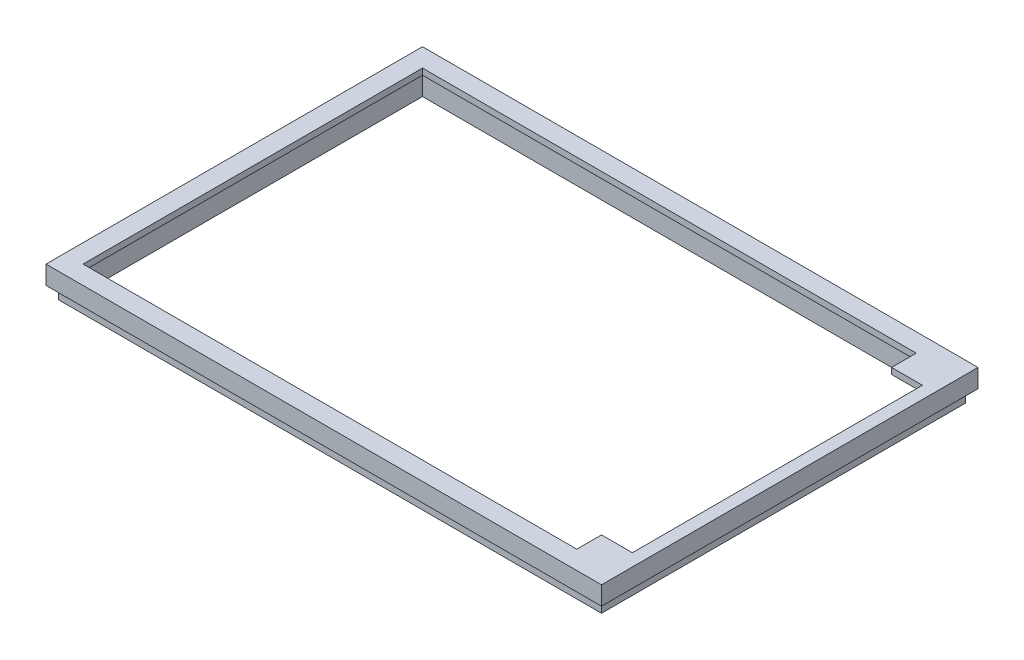
from build123d import *

# Parameters (mm, degrees)
SKETCH1_W           = 90
SKETCH1_H           = 61
SKETCH1_W_2         = 86
SKETCH1_H_2         = 57
BOSS_EXTRUDE1_DEPTH = 3
BOSS_EXTRUDE2_DEPTH = 1
SKETCH3_W           = 88
SKETCH3_H           = 59
SKETCH3_W_2         = 86
SKETCH3_H_2         = 57
BOSS_EXTRUDE3_DEPTH = 2


with BuildPart() as part:
    # Sketch1 → Boss-Extrude1 (new body)
    with BuildSketch(Plane(origin=(0, 0, 0), x_dir=(1, 0, 0), z_dir=(0, 1, 0))):
        with Locations((45, 30.5)):
            Rectangle(SKETCH1_W, SKETCH1_H)
        with Locations((45, 30.5)):
            Rectangle(SKETCH1_W_2, SKETCH1_H_2, mode=Mode.SUBTRACT)
    extrude(amount=BOSS_EXTRUDE1_DEPTH)

    # Sketch2 → Boss-Extrude2 (add)
    with BuildSketch(Plane(origin=(0, 3, 0), x_dir=(1, 0, 0), z_dir=(0, 1, 0))):
        Polygon((88, 59), (83, 59), (3, 59), (2, 59), (2, 2), (3, 2), (83, 2), (88, 2), (88, 7), (83, 7), (83, 3), (3, 3), (3, 58), (83, 58), (83, 54), (88, 54), align=None)
    extrude(amount=-BOSS_EXTRUDE2_DEPTH)

    # Sketch3 → Boss-Extrude3 (add)
    with BuildSketch(Plane.XZ):
        with Locations((45, -30.5)):
            Rectangle(SKETCH3_W, SKETCH3_H)
        with Locations((45, -30.5)):
            Rectangle(SKETCH3_W_2, SKETCH3_H_2, mode=Mode.SUBTRACT)
    extrude(amount=BOSS_EXTRUDE3_DEPTH)


solid = part.part
